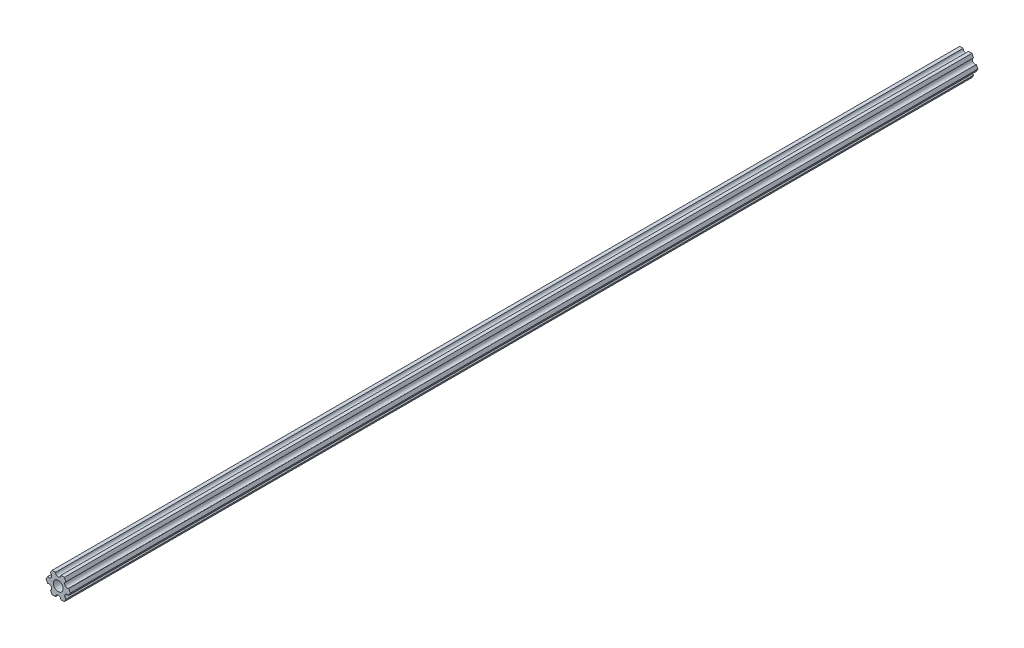
from build123d import *

# Parameters (mm, degrees)
SKETCH1_R           = 2.9337
BOSS_EXTRUDE1_DEPTH = 546.1


with BuildPart() as part:
    # Sketch1 → Boss-Extrude1 (new body)
    with BuildSketch(Plane(origin=(0, 0, 0), x_dir=(-1, 0, 0), z_dir=(0, 0, -1))):
        with BuildLine():
            Line((-4.70551159, -4.549815043), (-3.666174521, -6.349999904))
            Line((-3.666174521, -6.349999904), (-1.587500385, -6.349999904))
            ThreePointArc((-1.587500385, -6.349999904), (-3.85e-07, -4.762499904), (1.587499615, -6.349999904))
            Line((1.587499615, -6.349999904), (3.666173825, -6.349999904))
            Line((3.666173825, -6.349999904), (4.705510942, -4.54981524))
            ThreePointArc((4.705510942, -4.54981524), (4.124445629, -2.381249907), (6.293010962, -1.800184594))
            Line((6.293010962, -1.800184594), (7.332348079, 7e-08))
            Line((7.332348079, 7e-08), (6.293011217, 1.800184685))
            ThreePointArc((6.293011217, 1.800184685), (4.124445939, 2.381250203), (4.705511457, 4.549815481))
            Line((4.705511457, 4.549815481), (3.666174521, 6.350000222))
            Line((3.666174521, 6.350000222), (1.587500385, 6.350000222))
            ThreePointArc((1.587500385, 6.350000222), (3.85e-07, 4.762500222), (-1.587499615, 6.350000222))
            Line((-1.587499615, 6.350000222), (-3.666173825, 6.350000222))
            Line((-3.666173825, 6.350000222), (-4.705511038, 4.549815614))
            ThreePointArc((-4.705511038, 4.549815614), (-4.124445841, 2.38125025), (-6.293011205, 1.800185053))
            Line((-6.293011205, 1.800185053), (-7.332348419, 4.44e-07))
            Line((-7.332348419, 4.44e-07), (-6.293011423, -1.80018429))
            ThreePointArc((-6.293011423, -1.80018429), (-4.12444613, -2.38124975), (-4.70551159, -4.549815043))
        make_face()
        Circle(SKETCH1_R, mode=Mode.SUBTRACT)
    extrude(amount=-BOSS_EXTRUDE1_DEPTH)


solid = part.part
